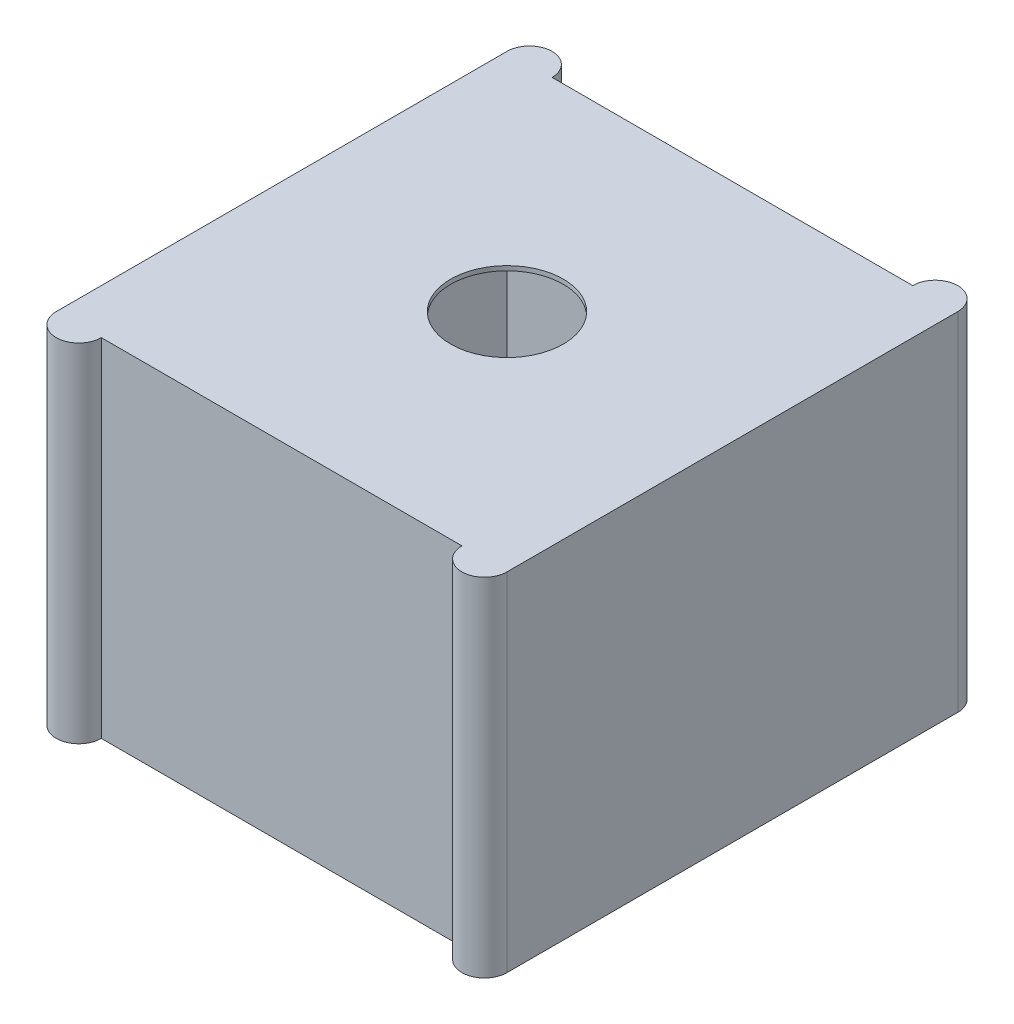
from build123d import *

# Parameters (mm, degrees)
SKETCH1_R           = 25
BOSS_EXTRUDE1_DEPTH = 154
SKETCH2_W           = 186
SKETCH2_H           = 186
CUT_EXTRUDE1_DEPTH  = 150


with BuildPart() as part:
    # Sketch1 → Boss-Extrude1 (new body)
    with BuildSketch(Plane(origin=(0, 0, 0), x_dir=(1, 0, 0), z_dir=(0, 1, 0))):
        with BuildLine():
            Line((-80, 100), (80, 100))
            ThreePointArc((80, 100), (90, 110), (100, 100))
            Line((100, 100), (100, -100))
            ThreePointArc((100, -100), (90, -110), (80, -100))
            Line((80, -100), (-80, -100))
            ThreePointArc((-80, -100), (-90, -110), (-100, -100))
            Line((-100, -100), (-100, 100))
            ThreePointArc((-100, 100), (-90, 110), (-80, 100))
        make_face()
        Circle(SKETCH1_R, mode=Mode.SUBTRACT)
    extrude(amount=BOSS_EXTRUDE1_DEPTH)

    # Sketch2 → Cut-Extrude1 (cut)
    with BuildSketch(Plane(origin=(0, 152, 0), x_dir=(1, 0, 0), z_dir=(0, 1, 0))):
        Rectangle(SKETCH2_W, SKETCH2_H)
    extrude(amount=-CUT_EXTRUDE1_DEPTH, mode=Mode.SUBTRACT)


solid = part.part
